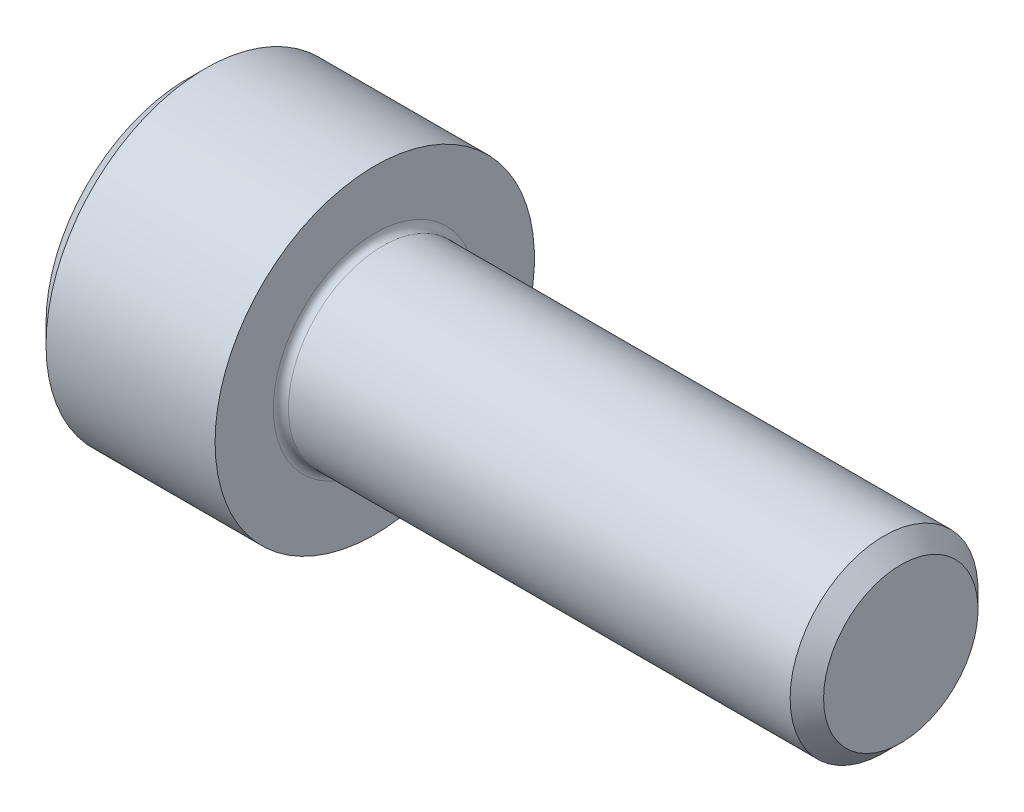
from build123d import *

# Parameters (mm, degrees)
FILLET1_R   = 0.2
HEX_2_DEPTH = 2.5


with BuildPart() as part:
    # BodySke → Base-Revolve (revolve)
    with BuildSketch(Plane.XY):
        Polygon((0, 0), (0, 3.75), (0.5, 4.25), (5, 4.25), (5, 2.5), (18.555, 2.5), (19, 2.055), (19, 0), align=None)
    revolve(axis=Axis((-31.75, 0, 0), (1, 0, 0)))

    # Fillet1
    fillet1_edges = [part.edges().sort_by_distance(p)[0] for p in [
        (5, -2.5, 0),
    ]]
    fillet(fillet1_edges, radius=FILLET1_R)

    # Sketch2 → Hex-PreBroach (revolve, cut)
    with BuildSketch(Plane.XY):
        Polygon((0, 2.042), (2.5, 2.042), (3.67894925, 0), (0, 0), align=None)
    revolve(axis=Axis((0, 0, 0), (1, 0, 0)), mode=Mode.SUBTRACT)

    # Sketch3 → Hex 2 (cut)
    with BuildSketch(Plane(origin=(0, 0, 0), x_dir=(0, 0.5, 0.866025404), z_dir=(-1, 0, 0))):
        Polygon((1.17894925, 2.042), (-1.17894925, 2.042), (-2.357898499, 0), (-1.17894925, -2.042), (1.17894925, -2.042), (2.357898499, 0), align=None)
    extrude(amount=-HEX_2_DEPTH, mode=Mode.SUBTRACT)


solid = part.part
